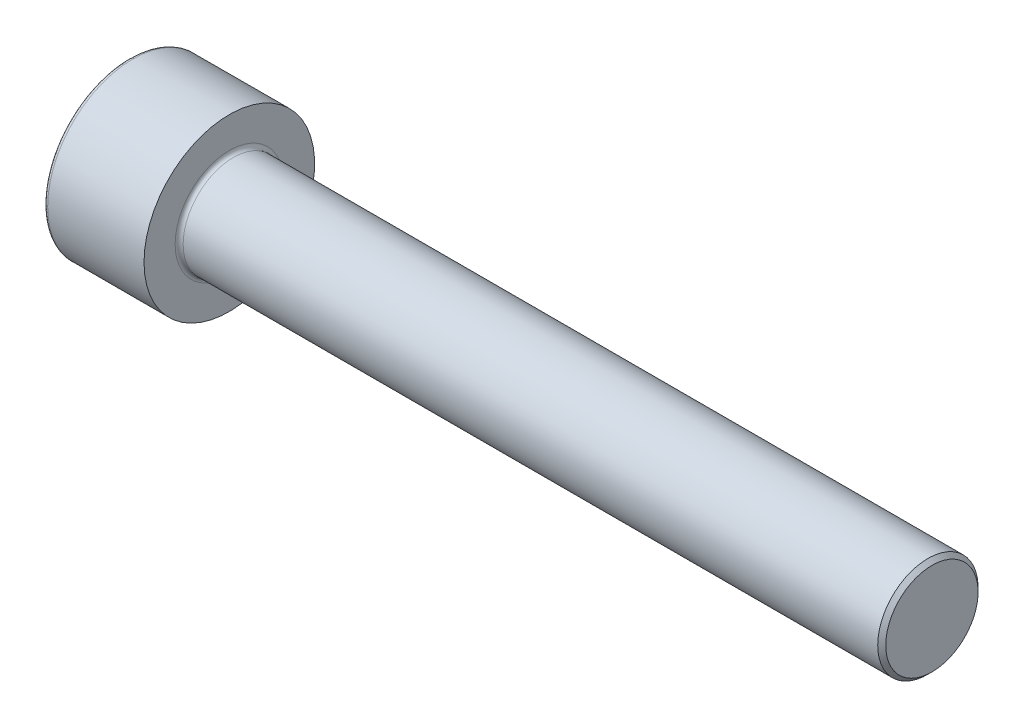
from build123d import *

# Parameters (mm, degrees)
CHAMFER_1_SIZE            = 0.2
FILLET_1_R                = 0.2
HOLE_WIZARD_4_0_4_1_D     = 4
HOLE_WIZARD_4_0_4_1_DEPTH = 2.5
HOLE_WIZARD_4_0_4_1_TIP   = 1.201721238
CUT_EXTRUDE_1_DEPTH       = 2.5
FILLET_2_R                = 0.2


with BuildPart() as part:
    # 草图1 → 旋转1 (revolve)
    with BuildSketch(Plane.XY):
        Polygon((0, 0), (0, 4.25), (5, 4.25), (5, 2.5), (40, 2.5), (40, 0), align=None)
    revolve(axis=Axis((0, 0, 0), (1, 0, 0)))

    # 倒角1
    chamfer_1_edges = [part.edges().sort_by_distance(p)[0] for p in [
        (40, -2.5, 0),
    ]]
    chamfer(chamfer_1_edges, length=CHAMFER_1_SIZE)

    # 圆角1
    fillet_1_edges = [part.edges().sort_by_distance(p)[0] for p in [
        (0, -4.25, 0),
    ]]
    fillet(fillet_1_edges, radius=FILLET_1_R)

    # Ø4.0 (4) 直径孔1
    with Locations(Plane.ZY):
        with Locations((0, 0)):
            Hole(HOLE_WIZARD_4_0_4_1_D / 2, depth=HOLE_WIZARD_4_0_4_1_DEPTH)
            with Locations((0, 0, -(HOLE_WIZARD_4_0_4_1_DEPTH + HOLE_WIZARD_4_0_4_1_TIP / 2))):  # 118° drill point
                Cone(0, HOLE_WIZARD_4_0_4_1_D / 2, HOLE_WIZARD_4_0_4_1_TIP, mode=Mode.SUBTRACT)

    # 草图2 → 切除-拉伸1 (cut)
    with BuildSketch(Plane.ZY):
        Polygon((0, -2.309401077), (2, -1.154700538), (2, 1.154700538), (0, 2.309401077), (-2, 1.154700538), (-2, -1.154700538), align=None)
    extrude(amount=-CUT_EXTRUDE_1_DEPTH, mode=Mode.SUBTRACT)

    # 圆角2
    fillet_2_edges = [part.edges().sort_by_distance(p)[0] for p in [
        (5, -2.5, 0),
    ]]
    fillet(fillet_2_edges, radius=FILLET_2_R)


solid = part.part
